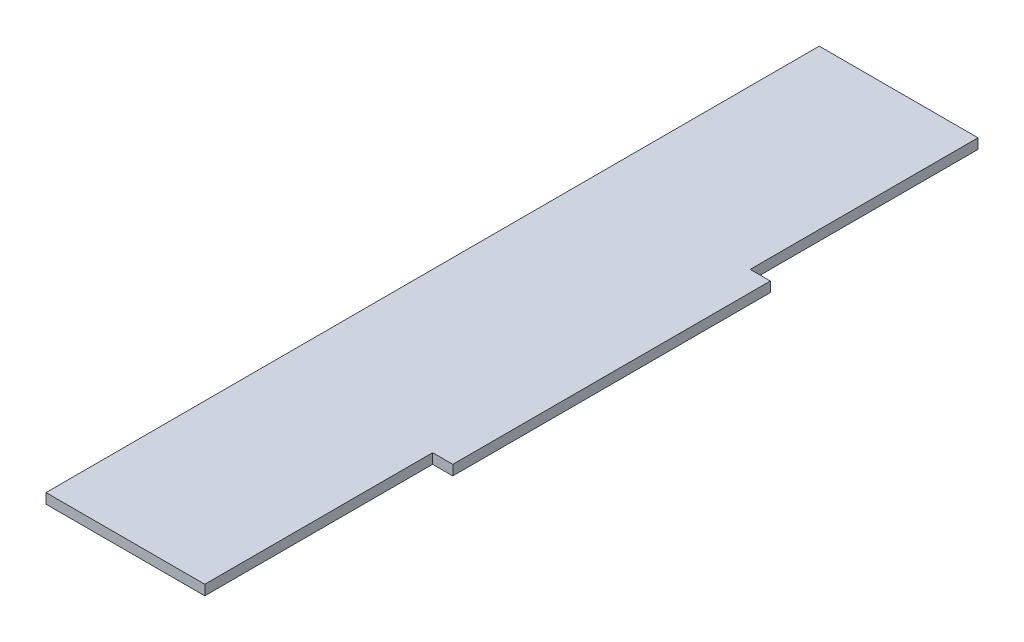
from build123d import *

# Parameters (mm, degrees)
BOSS_EXTRUDE1_DEPTH = 3.175


with BuildPart() as part:
    # Sketch1 → Boss-Extrude1 (new body)
    with BuildSketch(Plane(origin=(0, 0, 0), x_dir=(1, 0, 0), z_dir=(0, 1, 0))):
        Polygon((-25, 0), (-25, 71.75), (25, 71.75), (25, 0), (31.35, 0), (31.35, -100), (25, -100), (25, -171.75), (-25, -171.75), (-25, -100), align=None)
    extrude(amount=BOSS_EXTRUDE1_DEPTH)


solid = part.part
